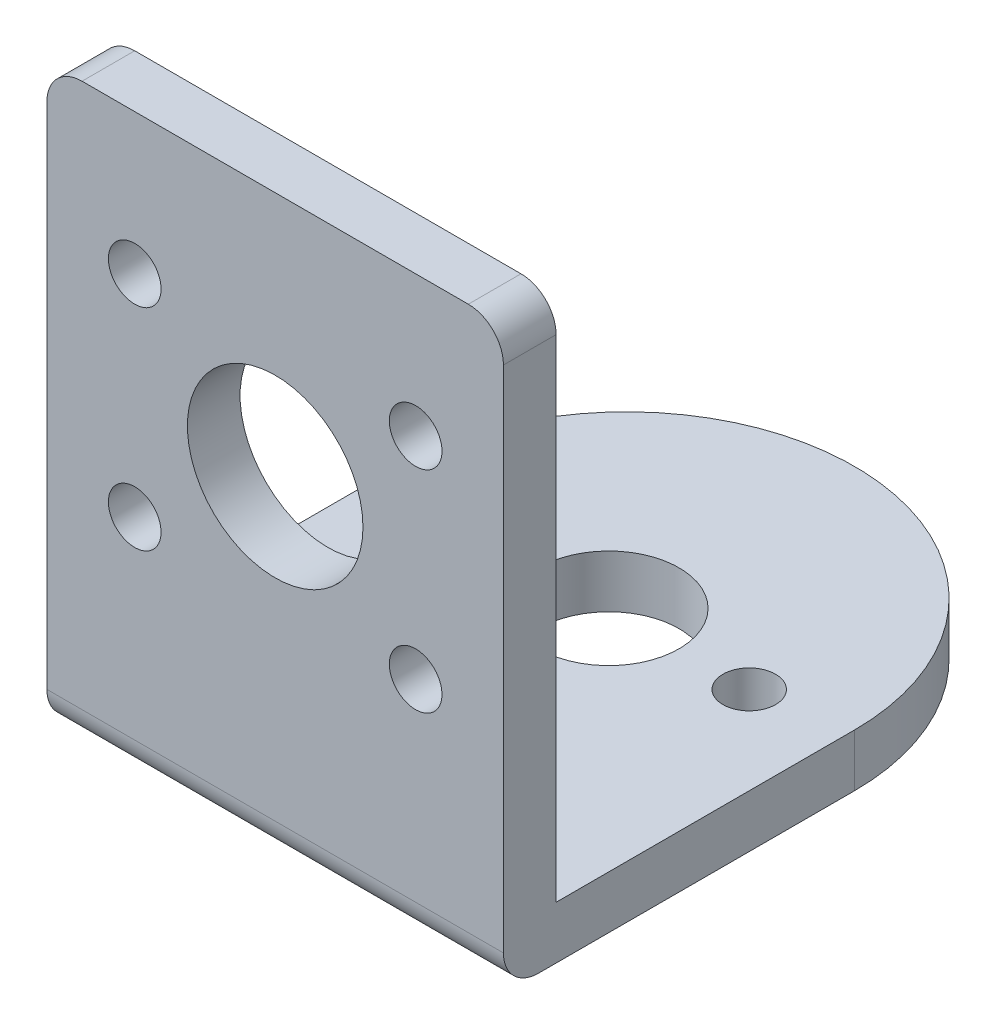
from build123d import *

# Parameters (mm, degrees)
SKETCH1_W           = 26
SKETCH1_H           = 33
SKETCH1_R           = 5
SKETCH1_R_2         = 1.5
BOSS_EXTRUDE1_DEPTH = 3
SKETCH2_W           = 26
SKETCH2_H           = 3
BOSS_EXTRUDE2_DEPTH = 30
SKETCH3_R           = 4
SKETCH3_R_2         = 1.5
CUT_EXTRUDE1_DEPTH  = 4
FILLET1_R           = 2
FILLET2_R           = 2


with BuildPart() as part:
    # Sketch1 → Boss-Extrude1 (new body)
    with BuildSketch(Plane.XY):
        Rectangle(SKETCH1_W, SKETCH1_H)
        with Locations((0, 2.5)):
            Circle(SKETCH1_R, mode=Mode.SUBTRACT)
        with Locations((-8, 8.5)):
            Circle(SKETCH1_R_2, mode=Mode.SUBTRACT)
        with Locations((8, 8.5)):
            Circle(SKETCH1_R_2, mode=Mode.SUBTRACT)
        with Locations((8, -3.5)):
            Circle(SKETCH1_R_2, mode=Mode.SUBTRACT)
        with Locations((-8, -3.5)):
            Circle(SKETCH1_R_2, mode=Mode.SUBTRACT)
    extrude(amount=BOSS_EXTRUDE1_DEPTH)

    # Sketch2 → Boss-Extrude2 (add)
    with BuildSketch(Plane(origin=(0, 0, 0), x_dir=(-1, 0, 0), z_dir=(0, 0, -1))):
        with Locations((0, -15)):
            Rectangle(SKETCH2_W, SKETCH2_H)
    extrude(amount=BOSS_EXTRUDE2_DEPTH)

    # Sketch3 → Cut-Extrude1 (cut, through all)
    with BuildSketch(Plane(origin=(0, -13.5, 0), x_dir=(1, 0, 0), z_dir=(0, 1, 0))):
        with BuildLine():
            Line((0, 30), (-13, 30))
            Line((-13, 30), (-13, 17))
            ThreePointArc((-13, 17), (-9.192388155, 26.192388155), (0, 30))
        make_face()
        with BuildLine():
            Line((13, 30), (0, 30))
            ThreePointArc((0, 30), (9.192388162, 26.192388149), (13, 16.999999981))
            Line((13, 16.999999981), (13, 30))
        make_face()
        with Locations((0, 16)):
            Circle(SKETCH3_R)
        with Locations((-8, 16)):
            Circle(SKETCH3_R_2)
        with Locations((8, 16)):
            Circle(SKETCH3_R_2)
    extrude(amount=-CUT_EXTRUDE1_DEPTH, mode=Mode.SUBTRACT)

    # Fillet1
    fillet1_edges = [part.edges().sort_by_distance(p)[0] for p in [
        (-13, 16.5, 1.5),
        (13, 16.5, 1.5),
    ]]
    fillet(fillet1_edges, radius=FILLET1_R)

    # Fillet2
    fillet2_edges = [part.edges().sort_by_distance(p)[0] for p in [
        (0, -16.5, 3),
    ]]
    fillet(fillet2_edges, radius=FILLET2_R)


solid = part.part
